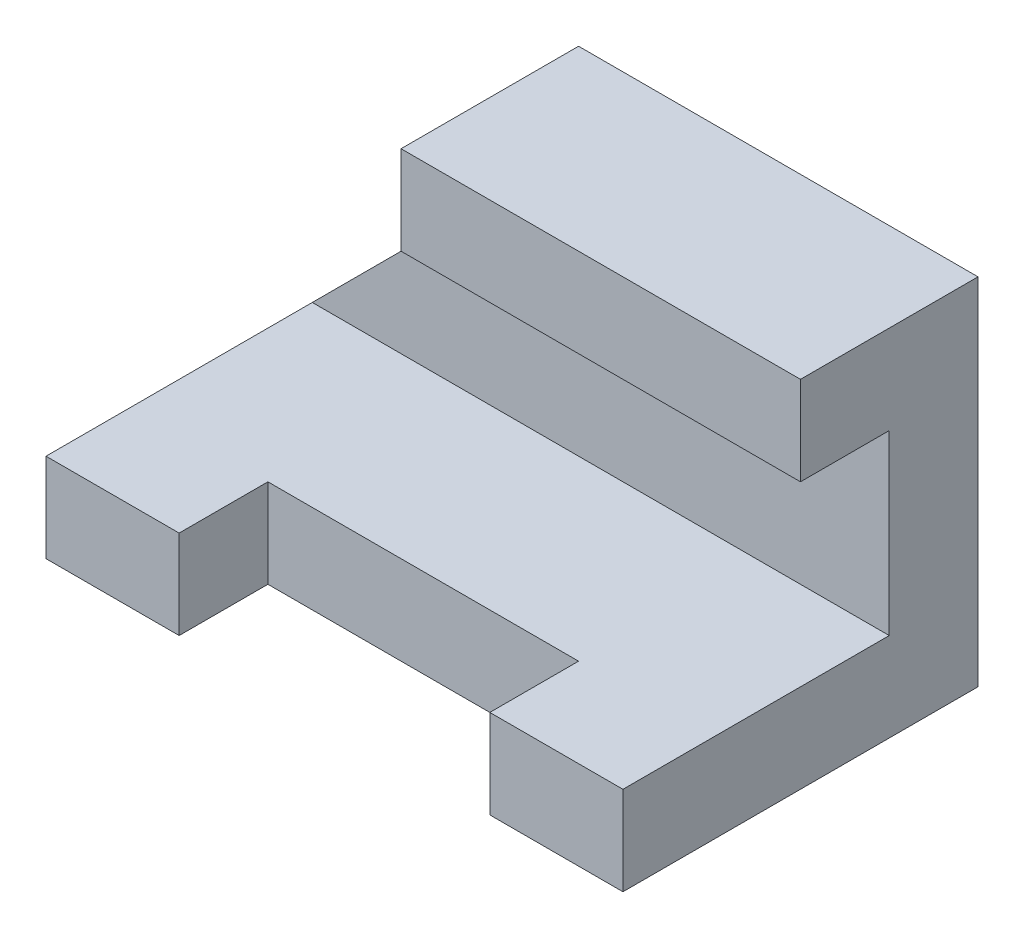
from build123d import *

# Parameters (mm, degrees)
BOSS_EXTRUDE1_DEPTH = 8
CUT_EXTRUDE1_DEPTH  = 18
SKETCH3_W           = 7
SKETCH3_H           = 2
CUT_EXTRUDE2_DEPTH  = 2


with BuildPart() as part:
    # Sketch1 → Boss-Extrude1 (new body)
    with BuildSketch(Plane.XY):
        Polygon((0, 0), (13, 0), (13, 8), (4, 8), (4, 6), (0, 2), align=None)
    extrude(amount=BOSS_EXTRUDE1_DEPTH)

    # Sketch2 → Cut-Extrude1 (cut)
    with BuildSketch(Plane(origin=(13, 0, 0), x_dir=(0, 0, -1), z_dir=(1, 0, 0))):
        Polygon((-8, 8), (-4, 8), (-4, 6), (-2, 6), (-2, 2), (-8, 2), (-8, 6), align=None)
    extrude(amount=-CUT_EXTRUDE1_DEPTH, mode=Mode.SUBTRACT)

    # Sketch3 → Cut-Extrude2 (cut)
    with BuildSketch(Plane(origin=(0, 2, 0), x_dir=(1, 0, 0), z_dir=(0, 1, 0))):
        with Locations((6.5, -7)):
            Rectangle(SKETCH3_W, SKETCH3_H)
    extrude(amount=-CUT_EXTRUDE2_DEPTH, mode=Mode.SUBTRACT)


solid = part.part
